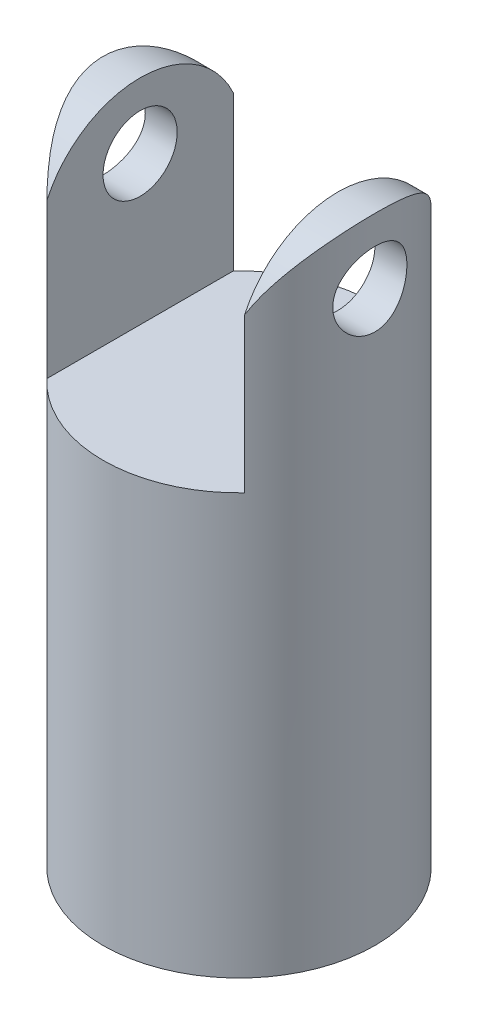
from build123d import *

# Parameters (mm, degrees)
SKETCH_1_R          = 5.5
EXTRUDE_1_DEPTH     = 26
SKETCH_2_W          = 8
SKETCH_2_H          = 18
CUT_EXTRUDE_1_DEPTH = 25
SKETCH_3_R          = 1.5
CUT_EXTRUDE_2_DEPTH = 25
CUT_EXTRUDE_3_DEPTH = 11


with BuildPart() as part:
    # 草图1 → 凸台-拉伸1 (new body)
    with BuildSketch(Plane(origin=(0, 0, 0), x_dir=(1, 0, 0), z_dir=(0, 1, 0))):
        Circle(SKETCH_1_R)
    extrude(amount=EXTRUDE_1_DEPTH)

    # 草图2 → 切除-拉伸1 (cut, symmetric)
    with BuildSketch(Plane.XY):
        with Locations((0, 26)):
            Rectangle(SKETCH_2_W, SKETCH_2_H)
    extrude(amount=CUT_EXTRUDE_1_DEPTH, both=True, mode=Mode.SUBTRACT)

    # 草图3 → 切除-拉伸2 (cut, symmetric)
    with BuildSketch(Plane(origin=(-4, 0, 0), x_dir=(0, 0, -1), z_dir=(1, 0, 0))):
        with Locations((0, 23)):
            Circle(SKETCH_3_R)
    extrude(amount=CUT_EXTRUDE_2_DEPTH, both=True, mode=Mode.SUBTRACT)

    # 草图5 → 切除-拉伸3 (cut, symmetric)
    with BuildSketch(Plane(origin=(0, 0, 0), x_dir=(0, 0, -1), z_dir=(1, 0, 0))):
        with BuildLine():
            Line((-4.153311931, 21.5), (-12.215121886, 24.91830584))
            Line((-12.215121886, 24.91830584), (0.629850505, 32.78071868))
            Line((0.629850505, 32.78071868), (12.991410006, 24.598657791))
            Line((12.991410006, 24.598657791), (4.153311931, 21.5))
            ThreePointArc((4.153311931, 21.5), (0, 25.653311931), (-4.153311931, 21.5))
        make_face()
    extrude(amount=CUT_EXTRUDE_3_DEPTH, both=True, mode=Mode.SUBTRACT)


solid = part.part
